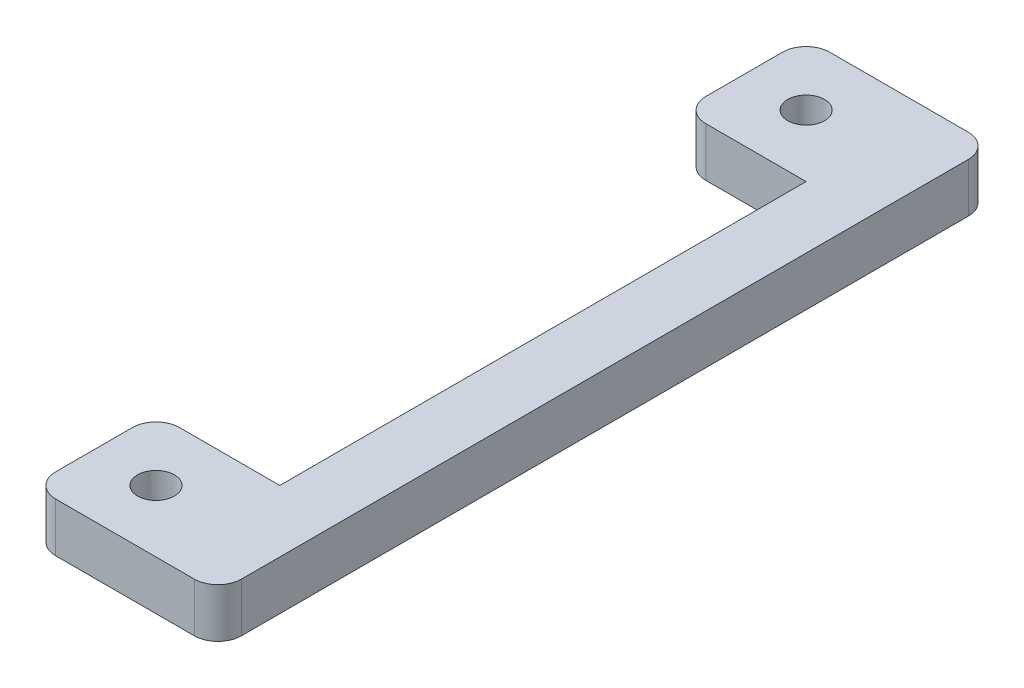
from build123d import *

# Parameters (mm, degrees)
SKETCH1_R           = 0.59563
BOSS_EXTRUDE1_DEPTH = 1.5875
FILLET1_R           = 0.762


with BuildPart() as part:
    # Sketch1 → Boss-Extrude1 (new body)
    with BuildSketch(Plane(origin=(0, 0, 0), x_dir=(1, 0, 0), z_dir=(0, 1, 0))):
        Polygon((0, 25), (4, 25), (6, 25), (6, 0), (4, 0), (0, 0), (0, 4), (4, 4), (4, 21), (0, 21), align=None)
        with Locations((2, 23)):
            Circle(SKETCH1_R, mode=Mode.SUBTRACT)
        with Locations((2, 2)):
            Circle(SKETCH1_R, mode=Mode.SUBTRACT)
    extrude(amount=BOSS_EXTRUDE1_DEPTH)

    # Fillet1
    fillet1_edges = [part.edges().sort_by_distance(p)[0] for p in [
        (6, 0.79375, -25),
        (6, 0.79375, 0),
        (0, 0.79375, 0),
        (0, 0.79375, -4),
        (0, 0.79375, -21),
        (0, 0.79375, -25),
    ]]
    fillet(fillet1_edges, radius=FILLET1_R)


solid = part.part
